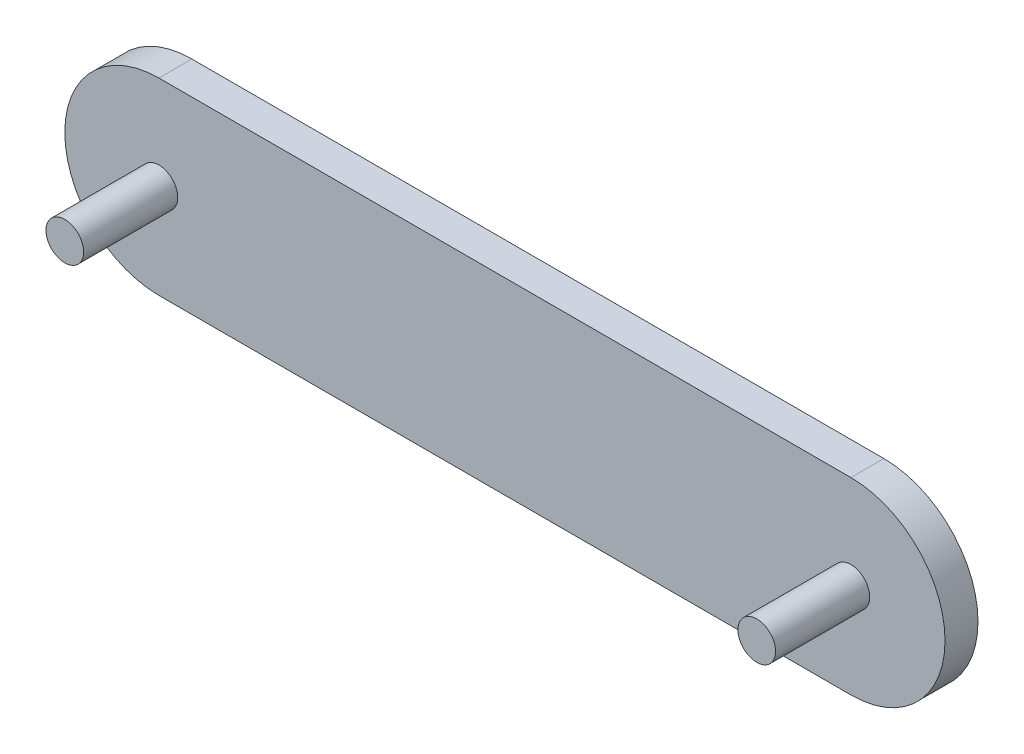
from build123d import *

# Parameters (mm, degrees)
BOSS_EXTRUDE1_DEPTH = 7
SKETCH3_R           = 4
BOSS_EXTRUDE2_DEPTH = 20
SKETCH4_R           = 4
BOSS_EXTRUDE3_DEPTH = 20


with BuildPart() as part:
    # Sketch2 → Boss-Extrude1 (new body)
    with BuildSketch(Plane.XY):
        with BuildLine():
            Line((0, 0), (147, 0))
            ThreePointArc((147, 0), (167, 20), (147, 40))
            Line((147, 40), (0, 40))
            ThreePointArc((0, 40), (-20, 20), (0, 0))
        make_face()
    extrude(amount=BOSS_EXTRUDE1_DEPTH)

    # Sketch3 → Boss-Extrude2 (add)
    with BuildSketch(Plane.XY.offset(7)):
        with Locations((147, 20)):
            Circle(SKETCH3_R)
    extrude(amount=BOSS_EXTRUDE2_DEPTH)

    # Sketch4 → Boss-Extrude3 (add)
    with BuildSketch(Plane.XY.offset(7)):
        with Locations((0, 20)):
            Circle(SKETCH4_R)
    extrude(amount=BOSS_EXTRUDE3_DEPTH)


solid = part.part
